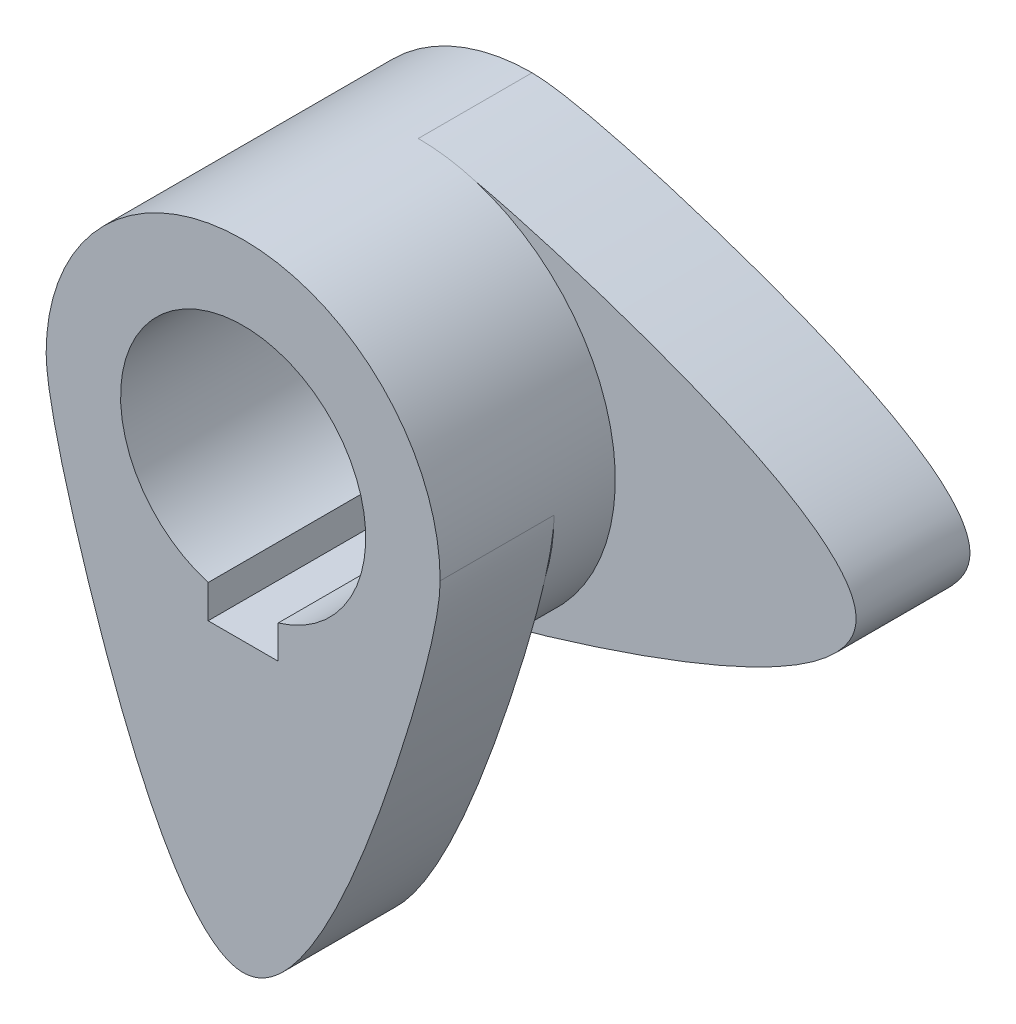
from build123d import *

# Parameters (mm, degrees)
SKETCH_1_R          = 14
EXTRUDE_1_DEPTH     = 13
SKETCH_2_R          = 22.5
EXTRUDE_2_DEPTH     = 7
EXTRUDE_3_DEPTH     = 13
SKETCH_4_R          = 14
CUT_EXTRUDE_1_DEPTH = 40
CUT_EXTRUDE_2_DEPTH = 41


with BuildPart() as part:
    # 草图1 → 凸台-拉伸1 (new body)
    with BuildSketch(Plane.XY):
        with BuildLine():
            ThreePointArc((0, 22.5), (-22.5, 0), (0, -22.5))
            add(Edge.make_bspline(
                [(0, 22.5), (3.74256312, 22.5), (25.152008405, 16.944120599), (65.295682957, 0), (25.155025761, -16.944120599), (3.738346709, -22.5), (0, -22.5)],
                knots=[0, 0, 0, 0, 0.192196215, 0.5, 0.807803785, 1, 1, 1, 1], degree=3))
        make_face()
        Circle(SKETCH_1_R, mode=Mode.SUBTRACT)
    extrude(amount=EXTRUDE_1_DEPTH)

    # 草图2 → 凸台-拉伸2 (add)
    with BuildSketch(Plane.XY.offset(13)):
        Circle(SKETCH_2_R)
    extrude(amount=EXTRUDE_2_DEPTH)

    # 草图3 → 凸台-拉伸3 (add)
    with BuildSketch(Plane.XY.offset(20)):
        with BuildLine():
            ThreePointArc((22.5, 0), (0, 22.5), (-22.5, 0))
            add(Edge.make_bspline(
                [(22.5, 0), (22.5, -3.74256312), (16.944120599, -25.152008405), (0, -65.295682957), (-16.944120599, -25.155025761), (-22.5, -3.738346709), (-22.5, 0)],
                knots=[0, 0, 0, 0, 0.192196215, 0.5, 0.807803785, 1, 1, 1, 1], degree=3))
        make_face()
    extrude(amount=EXTRUDE_3_DEPTH)

    # 草图4 → 切除-拉伸1 (cut)
    with BuildSketch(Plane(origin=(0, 0, 13), x_dir=(-1, 0, 0), z_dir=(0, 0, -1))):
        Circle(SKETCH_4_R)
    extrude(amount=-CUT_EXTRUDE_1_DEPTH, mode=Mode.SUBTRACT)

    # 草图5 → 切除-拉伸2 (cut)
    with BuildSketch(Plane.XY.offset(33)):
        Polygon((-4, -14), (-4, -9.153591973), (4, -9.153591973), (4, -14), (4, -17.2), (-4, -17.2), align=None)
    extrude(amount=-CUT_EXTRUDE_2_DEPTH, mode=Mode.SUBTRACT)


solid = part.part
